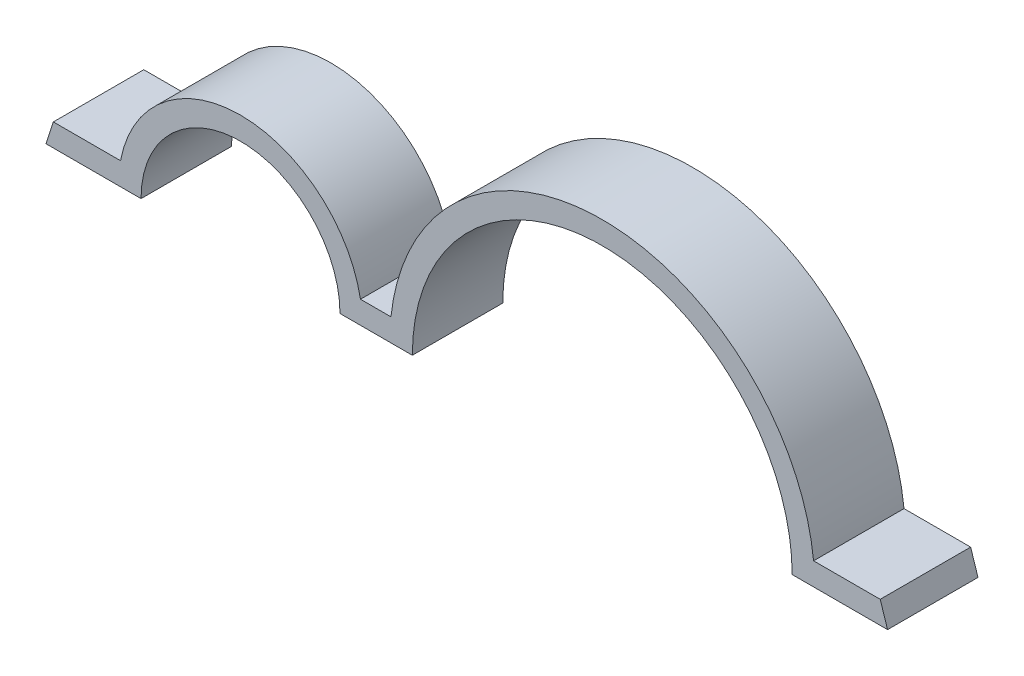
from build123d import *

# Parameters (mm, degrees)
BOSS_EXTRUDE2_DEPTH = 6.35


with BuildPart() as part:
    # Sketch1 → Boss-Extrude2 (new body)
    with BuildSketch(Plane.XY):
        with BuildLine():
            Line((-29.545241798, 172.775844825), (-22.8727, 172.775844825))
            ThreePointArc((-22.8727, 172.775844825), (-15.8877, 179.760844825), (-8.9027, 172.775844825))
            Line((-8.9027, 172.775844825), (-3.8227, 172.775844825))
            ThreePointArc((-3.8227, 172.775844825), (9.5123, 186.110844825), (22.8473, 172.775844825))
            Line((22.8473, 172.775844825), (29.545241798, 172.775844825))
            Line((29.545241798, 172.775844825), (29.028734718, 174.363344825))
            Line((29.028734718, 174.363344825), (24.350118236, 174.363344825))
            ThreePointArc((24.350118236, 174.363344825), (9.5123, 187.698344825), (-5.325518236, 174.363344825))
            Line((-5.325518236, 174.363344825), (-7.463473032, 174.363344825))
            ThreePointArc((-7.463473032, 174.363344825), (-15.8877, 181.348344825), (-24.311926968, 174.363344825))
            Line((-24.311926968, 174.363344825), (-29.028734718, 174.363344825))
            Line((-29.028734718, 174.363344825), (-29.545241798, 172.775844825))
        make_face()
    extrude(amount=BOSS_EXTRUDE2_DEPTH)


solid = part.part
